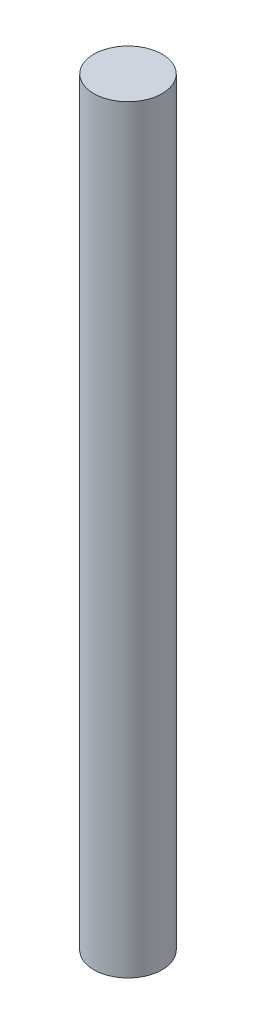
from build123d import *

# Parameters (mm, degrees)
CROQUIS1_R              = 4.5
SALIENTE_EXTRUIR1_DEPTH = 100


with BuildPart() as part:
    # Croquis1 → Saliente-Extruir1 (new body)
    with BuildSketch(Plane(origin=(0, 0, 0), x_dir=(1, 0, 0), z_dir=(0, 1, 0))):
        Circle(CROQUIS1_R)
    extrude(amount=SALIENTE_EXTRUIR1_DEPTH)


solid = part.part
